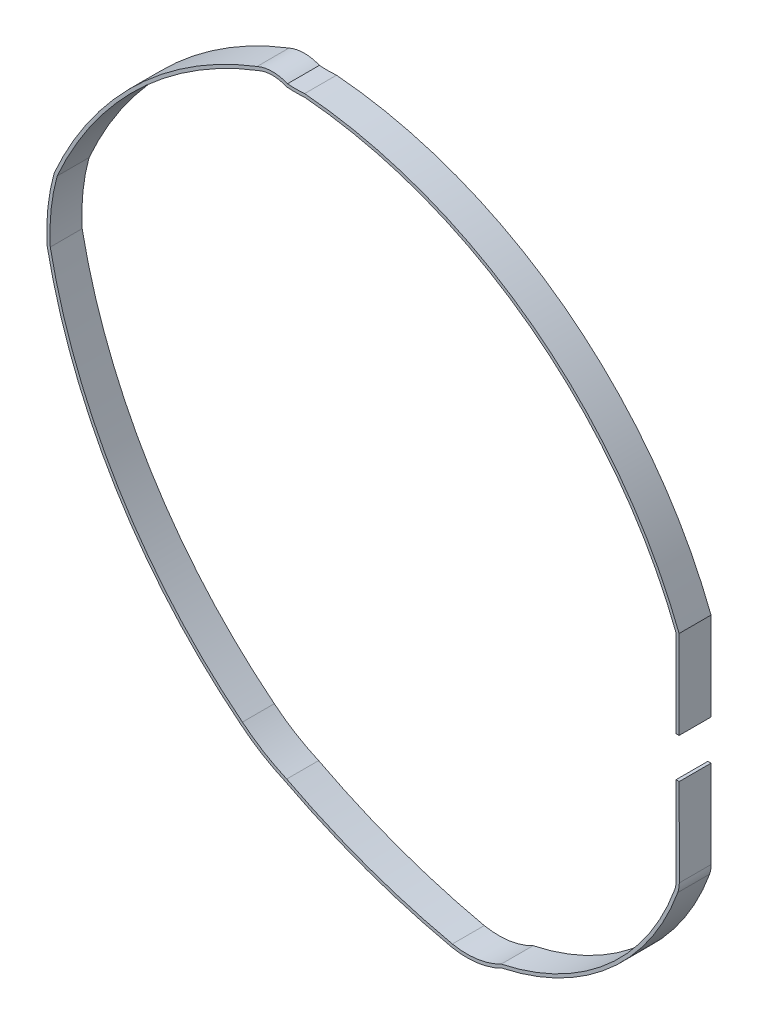
from build123d import *

# Parameters (mm, degrees)
EXTRUDE_1_DEPTH = 4


with BuildPart() as part:
    # ｽｹｯﾁ1 → 押し出し-薄板1 (new body)
    with BuildSketch(Plane.XY):
        with BuildLine():
            Line((31.817918932, -48.177333301), (31.817918932, -37.177333301))
            ThreePointArc((31.817918932, -37.177333301), (13.522512959, -13.098535642), (-14.744222733, -2.35134858))
            ThreePointArc((-14.744222733, -2.35134858), (-15.865863397, -2.395137502), (-16.987504061, -2.35134858))
            ThreePointArc((-16.987504061, -2.35134858), (-18.769087239, -1.977100594), (-20.550670416, -2.35134858))
            ThreePointArc((-20.550670416, -2.35134858), (-35.568393968, -11.863545081), (-45.774892731, -26.418313577))
            ThreePointArc((-45.774892731, -26.418313577), (-46.541356838, -30.457424603), (-46.640707903, -34.567414199))
            ThreePointArc((-46.640707903, -34.567414199), (-38.091787933, -56.469515549), (-22.543394241, -74.105658262))
            ThreePointArc((-22.543394241, -74.105658262), (-19.883130575, -75.998799448), (-16.987504061, -77.507551719))
            ThreePointArc((-16.987504061, -77.507551719), (-6.850461885, -81.960889249), (3.785718261, -85.037171284))
            ThreePointArc((3.785718261, -85.037171284), (6.924298505, -85.121668583), (9.912563229, -84.158289278))
            ThreePointArc((9.912563229, -84.158289278), (23.249791669, -77.499086362), (31.664980135, -65.194158528))
            ThreePointArc((31.664980135, -65.194158528), (31.798207183, -64.69156991), (31.842654494, -64.173526282))
            Line((31.842654494, -64.173526282), (31.829698084, -53.173533912))
            Line((31.829698084, -53.173533912), (32.229697806, -53.17306277))
            Line((32.229697806, -53.17306277), (32.242654217, -64.17305514))
            ThreePointArc((32.242654217, -64.17305514), (32.192280597, -64.760171252), (32.041289943, -65.329771685))
            ThreePointArc((32.041289943, -65.329771685), (23.533127113, -77.782723155), (10.048772084, -84.538239753))
            ThreePointArc((10.048772084, -84.538239753), (6.951896278, -85.521759001), (3.703928148, -85.428738073))
            ThreePointArc((3.703928148, -85.428738073), (-6.978540006, -82.339930506), (-17.160076645, -77.868670088))
            ThreePointArc((-17.160076645, -77.868670088), (-20.096654101, -76.337084696), (-22.795002474, -74.416627193))
            ThreePointArc((-22.795002474, -74.416627193), (-38.441353007, -56.664552527), (-47.038422063, -34.618354588))
            ThreePointArc((-47.038422063, -34.618354588), (-46.939059251, -30.414609925), (-46.152726889, -26.283868638))
            ThreePointArc((-46.152726889, -26.283868638), (-35.858331906, -11.587325271), (-20.702879093, -1.981326883))
            ThreePointArc((-20.702879093, -1.981326883), (-18.799199915, -1.577194509), (-16.890627411, -1.957547479))
            ThreePointArc((-16.890627411, -1.957547479), (-15.816780094, -1.995051381), (-14.743222437, -1.950011819))
            ThreePointArc((-14.743222437, -1.950011819), (13.7790296, -12.790893821), (32.217918932, -37.10243314))
            Line((32.217918932, -37.10243314), (32.217918932, -48.177333301))
            Line((32.217918932, -48.177333301), (31.817918932, -48.177333301))
        make_face()
    extrude(amount=EXTRUDE_1_DEPTH)


solid = part.part
